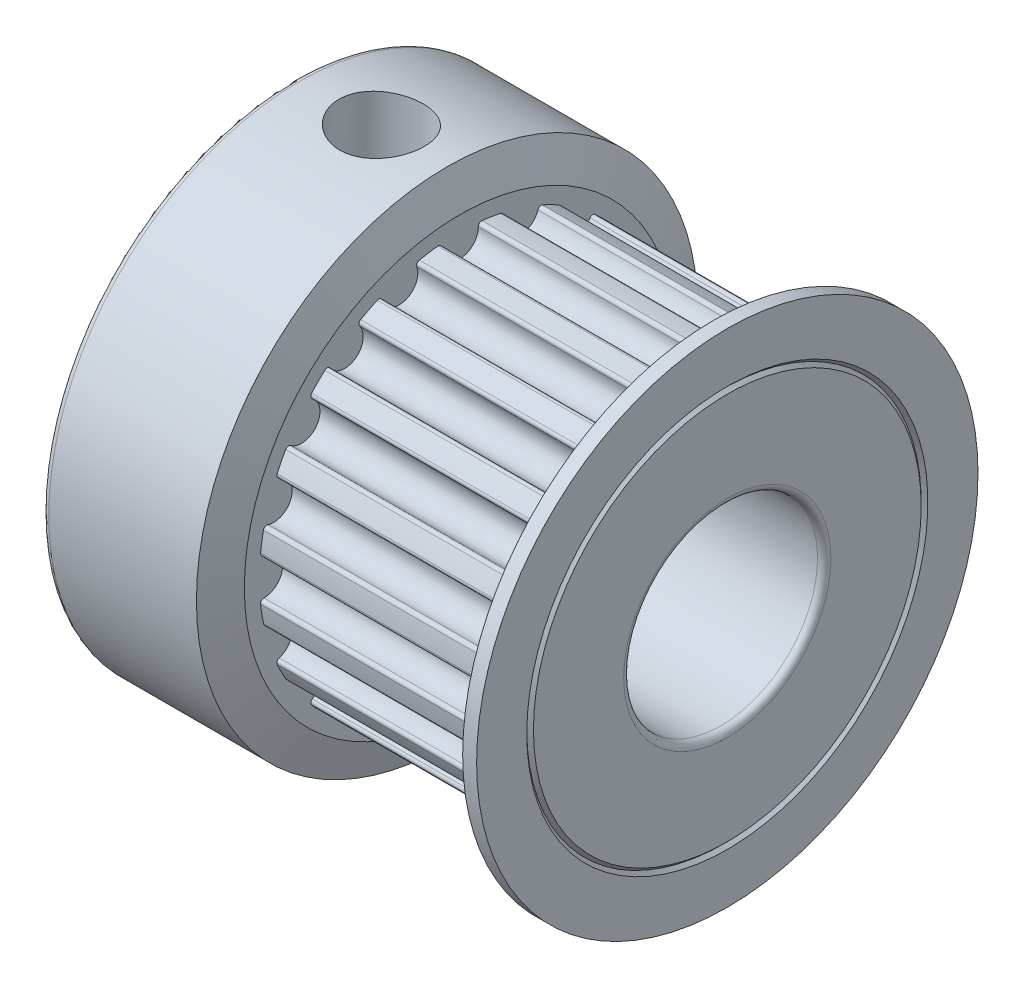
from build123d import *

# Parameters (mm, degrees)
SKETCH_3_R                = 0.55
CUT_EXTRUDE1_DEPTH        = 7.2
FILLET_2_R                = 0.1
CIRPATTERN1_COUNT         = 20
FILLET_2_OF_CIRPATTERN1_R = 0.1
M3_TAPPED_HOLE1_D         = 2.5
M3_TAPPED_HOLE1_DEPTH     = 7.5
M3_TAPPED_HOLE1_TIP       = 0.751075774
FILLET1_R                 = 0.2


with BuildPart() as part:
    # Sketch 1 → Body (revolve)
    with BuildSketch(Plane.XY):
        Polygon((1, 2.9), (1, 7.5), (5.617601306, 7.5), (6, 6.449368223), (6, 6), (13.2, 6), (13.2, 6.449368223), (13.582398694, 7.5), (14, 7.5), (14, 6), (13.9, 5.9), (14, 5.8), (14, 2.9), align=None)
    revolve(axis=Axis((1, 0, 0), (1, 0, 0)))

    # Sketch 3 → Cut-Extrude1 (cut)
    with BuildSketch(Plane(origin=(6, 0, 0), x_dir=(0, 0, -1), z_dir=(1, 0, 0))):
        with Locations((0, 5.855)):
            Circle(SKETCH_3_R)
    cut_extrude1 = extrude(amount=CUT_EXTRUDE1_DEPTH, mode=Mode.SUBTRACT)

    # Fillet 2
    fillet_2_edges = [part.edges().sort_by_distance(p)[0] for p in [
        (9.6, 5.975962852, -0.536533306),
        (9.6, 5.975962852, 0.536533306),
    ]]
    fillet(fillet_2_edges, radius=FILLET_2_R)

    # CirPattern1: Cut-Extrude1 ×20 about axis
    cirpattern1_axis = Axis((0, 0, 0), (1, 0, 0))
    for i in range(1, CIRPATTERN1_COUNT):
        add(cut_extrude1.rotate(cirpattern1_axis, i * 360 / CIRPATTERN1_COUNT), mode=Mode.SUBTRACT)

    # Fillet 2 of CirPattern1
    fillet_2_of_cirpattern1_edges = [part.edges().sort_by_distance(p)[0] for p in [
        (9.6, 5.849276321, 1.336400582),
        (9.6, 5.517680502, 2.356947576),
        (9.6, 5.15002187, 3.07851827),
        (9.6, 4.519289141, 3.946647395),
        (9.6, 3.946647395, 4.519289141),
        (9.6, 3.07851827, 5.15002187),
        (9.6, 2.356947576, 5.517680502),
        (9.6, 1.336400582, 5.849276321),
        (9.6, 0.536533306, 5.975962852),
        (9.6, -0.536533306, 5.975962852),
        (9.6, -1.336400582, 5.849276321),
        (9.6, -2.356947576, 5.517680502),
        (9.6, -3.07851827, 5.15002187),
        (9.6, -3.946647395, 4.519289141),
        (9.6, -4.519289141, 3.946647395),
        (9.6, -5.15002187, 3.07851827),
        (9.6, -5.517680502, 2.356947576),
        (9.6, -5.849276321, 1.336400582),
        (9.6, -5.975962852, 0.536533306),
        (9.6, -5.975962852, -0.536533306),
        (9.6, -5.849276321, -1.336400582),
        (9.6, -5.517680502, -2.356947576),
        (9.6, -5.15002187, -3.07851827),
        (9.6, -4.519289141, -3.946647395),
        (9.6, -3.946647395, -4.519289141),
        (9.6, -3.07851827, -5.15002187),
        (9.6, -2.356947576, -5.517680502),
        (9.6, -1.336400582, -5.849276321),
        (9.6, -0.536533306, -5.975962852),
        (9.6, 0.536533306, -5.975962852),
        (9.6, 1.336400582, -5.849276321),
        (9.6, 2.356947576, -5.517680502),
        (9.6, 3.07851827, -5.15002187),
        (9.6, 3.946647395, -4.519289141),
        (9.6, 4.519289141, -3.946647395),
        (9.6, 5.15002187, -3.07851827),
        (9.6, 5.517680502, -2.356947576),
        (9.6, 5.849276321, -1.336400582),
    ]]
    fillet(fillet_2_of_cirpattern1_edges, radius=FILLET_2_OF_CIRPATTERN1_R)

    # M3 Tapped Hole1
    with Locations(Plane(origin=(3.5, 7.498410891, -0.154382974), x_dir=(0, 0.020584397, 0.999788119), z_dir=(0, 0.999788119, -0.020584397))):
        with Locations((0, 0)):
            Hole(M3_TAPPED_HOLE1_D / 2, depth=M3_TAPPED_HOLE1_DEPTH)
            with Locations((0, 0, -(M3_TAPPED_HOLE1_DEPTH + M3_TAPPED_HOLE1_TIP / 2))):  # 118° drill point
                Cone(0, M3_TAPPED_HOLE1_D / 2, M3_TAPPED_HOLE1_TIP, mode=Mode.SUBTRACT)

    # Fillet1
    fillet1_edges = [part.edges().sort_by_distance(p)[0] for p in [
        (14, -2.9, 0),
        (1, -2.9, 0),
        (1, -7.5, 0),
        (4.403873365, 2.750121211, -0.920235496),
    ]]
    fillet(fillet1_edges, radius=FILLET1_R)


solid = part.part
